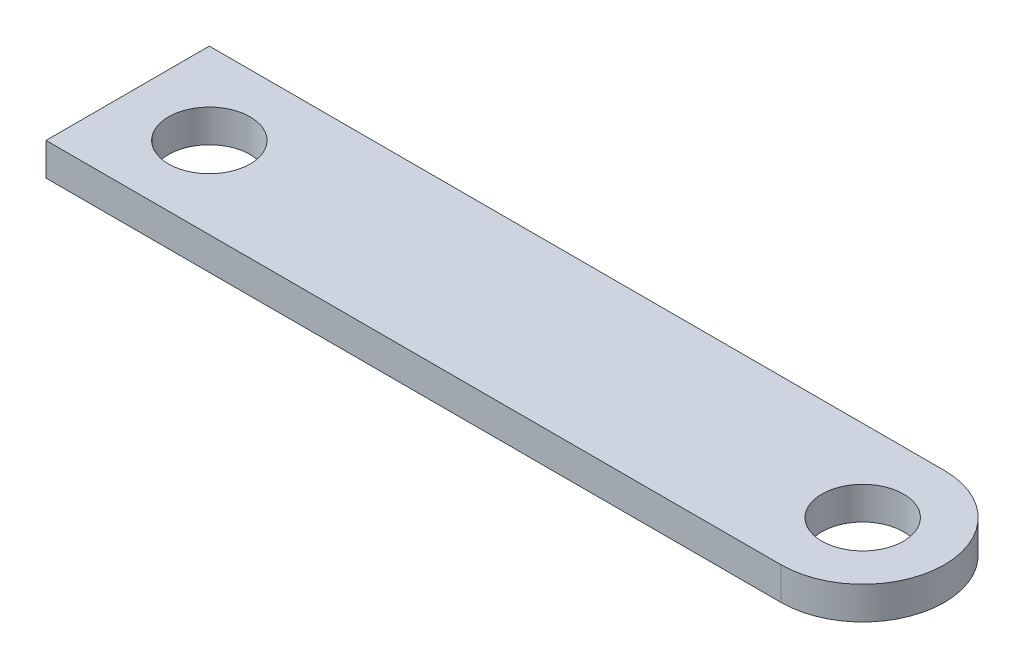
from build123d import *

# Parameters (mm, degrees)
SALIENTE_EXTRUIR2_DEPTH   = 2
SALIENTE_EXTRUIR2_2_DEPTH = 2
SALIENTE_EXTRUIR5_DEPTH   = 2


with BuildPart() as part:
    # Croquis1 → Saliente-Extruir2 (new body)
    with BuildSketch(Plane(origin=(0, 0, 0), x_dir=(1, 0, 0), z_dir=(0, 1, 0))):
        with BuildLine():
            Line((25, 0), (27.5, 0))
            ThreePointArc((27.5, 0), (22.5, 5), (17.5, 0))
            Line((17.5, 0), (20, 0))
            ThreePointArc((20, 0), (22.5, 2.5), (25, 0))
        make_face()
    extrude(amount=SALIENTE_EXTRUIR2_DEPTH)



with BuildPart() as body_2:
    # Croquis1 → Saliente-Extruir2 2 (new body)
    with BuildSketch(Plane(origin=(0, 0, 0), x_dir=(1, 0, 0), z_dir=(0, 1, 0))):
        with BuildLine():
            Line((-22.5, -5), (22.5, -5))
            ThreePointArc((22.5, -5), (18.964466094, -3.535533906), (17.5, 0))
            Line((17.5, 0), (-15, 0))
            ThreePointArc((-15, 0), (-17.5, -2.5), (-20, 0))
            Line((-20, 0), (-22.5, 0))
            Line((-22.5, 0), (-22.5, -5))
        make_face()
    extrude(amount=SALIENTE_EXTRUIR2_2_DEPTH)


with BuildPart() as part_1:
    add(part.part)

    add(body_2.part)  # Saliente-Extruir5 merges body 2
    # Croquis1_4 → Saliente-Extruir5 (add)
    with BuildSketch(Plane(origin=(0, 0, 0), x_dir=(1, 0, 0), z_dir=(0, 1, 0))):
        with BuildLine():
            Line((27.5, 0), (25, 0))
            ThreePointArc((25, 0), (22.5, -2.5), (20, 0))
            Line((20, 0), (17.5, 0))
            ThreePointArc((17.5, 0), (22.5, -5), (27.5, 0))
        make_face()
        with BuildLine():
            ThreePointArc((17.5, 0), (18.964466094, 3.535533906), (22.5, 5))
            Line((22.5, 5), (-22.5, 5))
            Line((-22.5, 5), (-22.5, 0))
            Line((-22.5, 0), (-20, 0))
            ThreePointArc((-20, 0), (-17.5, 2.5), (-15, 0))
            Line((-15, 0), (17.5, 0))
        make_face()
    extrude(amount=SALIENTE_EXTRUIR5_DEPTH)


solid = part_1.part
